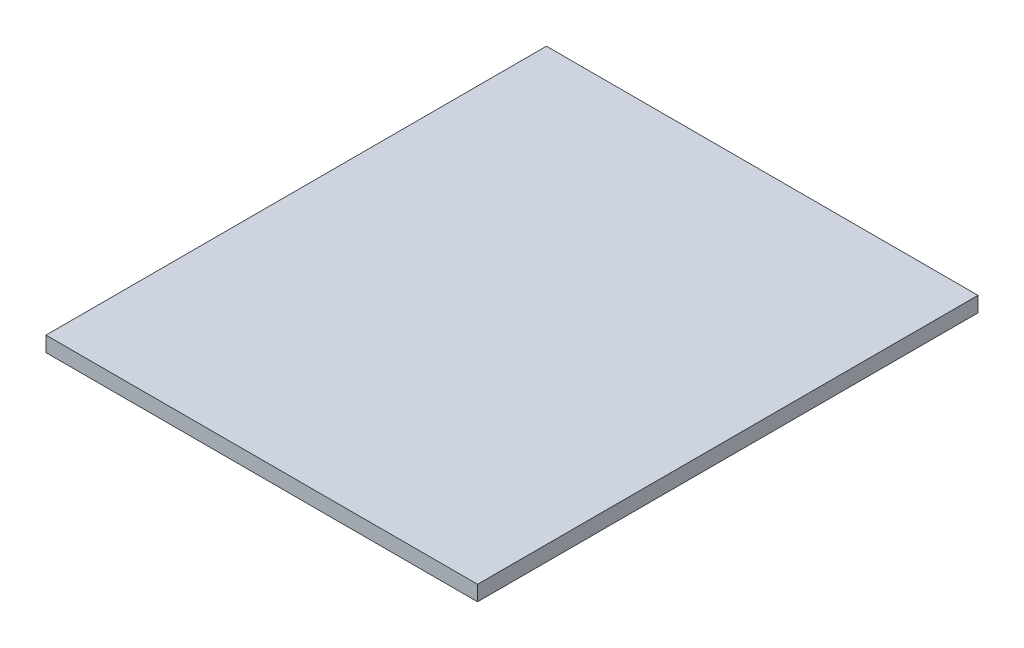
from build123d import *

# Parameters (mm, degrees)
SKETCH1_W           = 85.2
SKETCH1_H           = 98.8
BOSS_EXTRUDE1_DEPTH = 3


with BuildPart() as part:
    # Sketch1 → Boss-Extrude1 (new body)
    with BuildSketch(Plane(origin=(0, 0, 0), x_dir=(1, 0, 0), z_dir=(0, 1, 0))):
        with Locations((-1.681542056, -28.701985981)):
            Rectangle(SKETCH1_W, SKETCH1_H)
    extrude(amount=BOSS_EXTRUDE1_DEPTH)


solid = part.part
